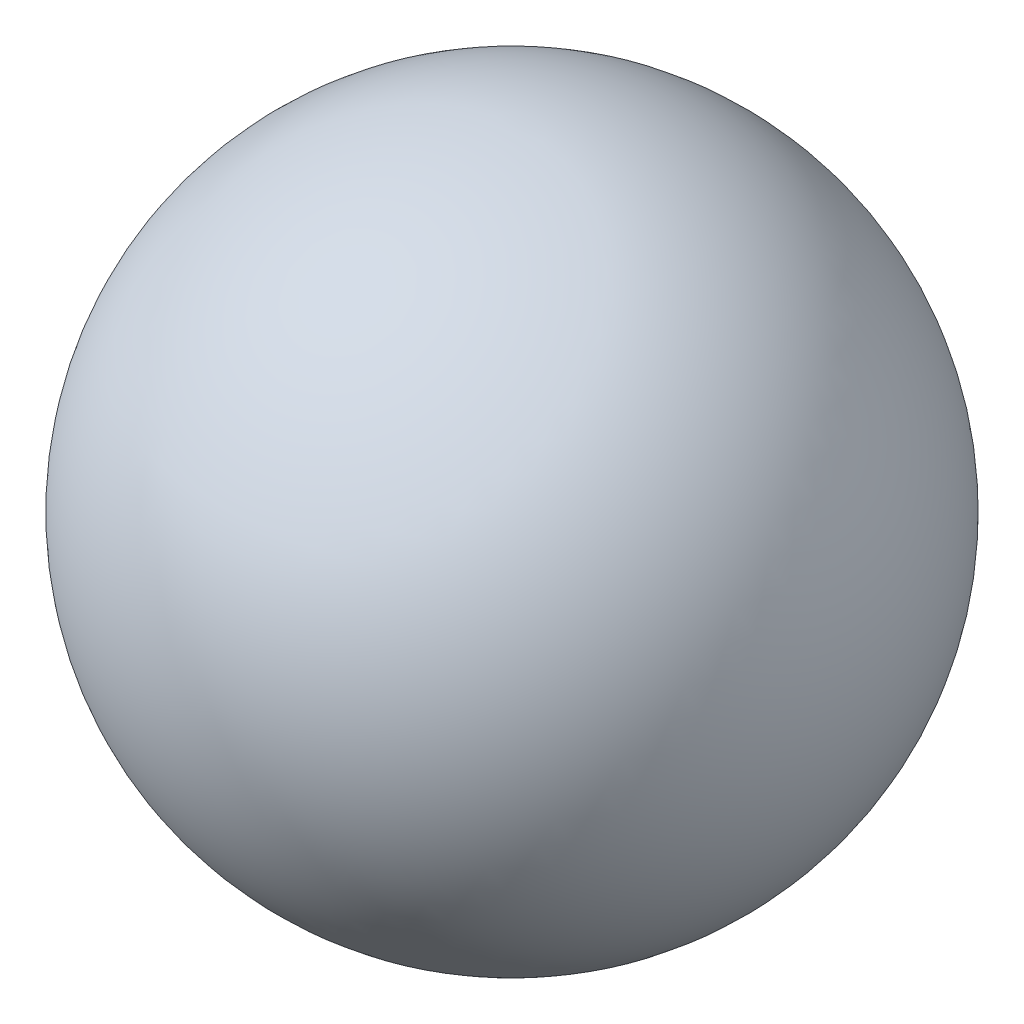
from build123d import *


with BuildPart() as part:
    # Esquisse1 → Base-Révolution (revolve)
    with BuildSketch(Plane.XY):
        with BuildLine():
            Line((2, 4.6), (2, 7.4))
            ThreePointArc((2, 7.4), (0.6, 6), (2, 4.6))
        make_face()
    revolve(axis=Axis((2, 8, 0), (0, 1, 0)))


solid = part.part
